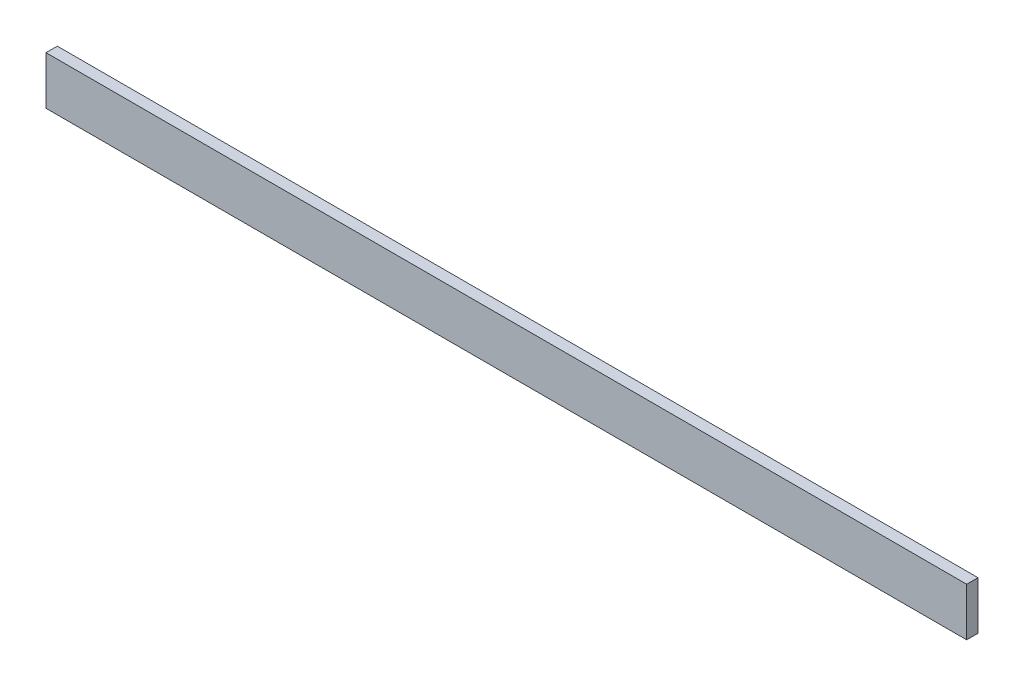
from build123d import *

# Parameters (mm, degrees)
SKETCH1_W           = 970.788
SKETCH1_H           = 50.8
BOSS_EXTRUDE1_DEPTH = 11.938


with BuildPart() as part:
    # Sketch1 → Boss-Extrude1 (new body)
    with BuildSketch(Plane.XY):
        Rectangle(SKETCH1_W, SKETCH1_H)
    extrude(amount=BOSS_EXTRUDE1_DEPTH)


solid = part.part
